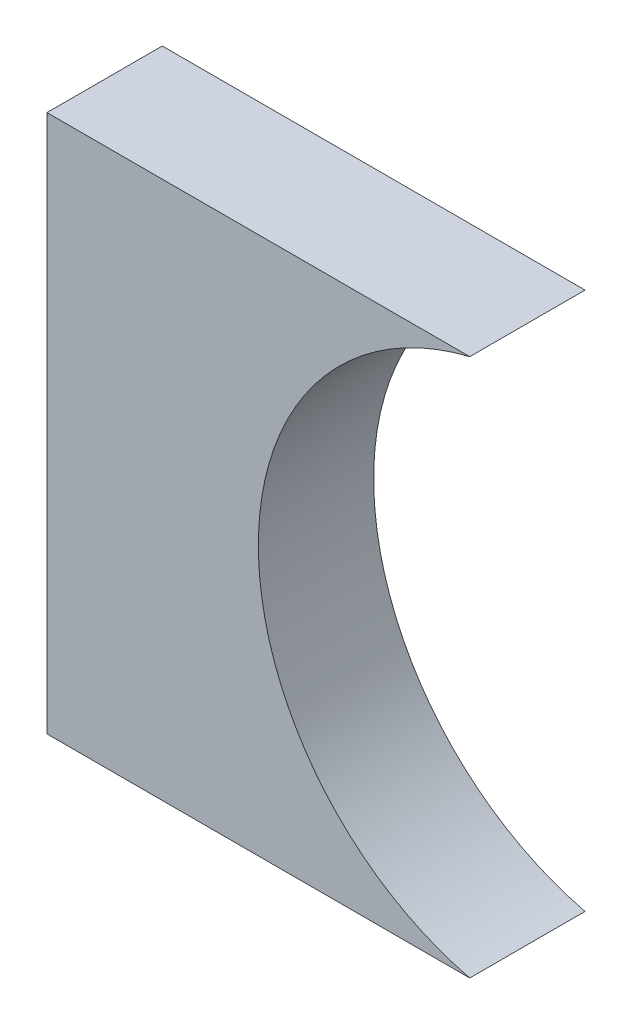
from build123d import *

# Parameters (mm, degrees)
BOSS_EXTRUDE1_DEPTH = 9.525


with BuildPart() as part:
    # Sketch1 → Boss-Extrude1 (new body, symmetric)
    with BuildSketch(Plane.XY):
        with BuildLine():
            ThreePointArc((34.925, 44.45), (0, 0), (34.925, -44.45))
            Line((34.925, -44.45), (-34.925, -44.45))
            Line((-34.925, -44.45), (-34.925, 44.45))
            Line((-34.925, 44.45), (34.925, 44.45))
        make_face()
    extrude(amount=BOSS_EXTRUDE1_DEPTH, both=True)


solid = part.part
